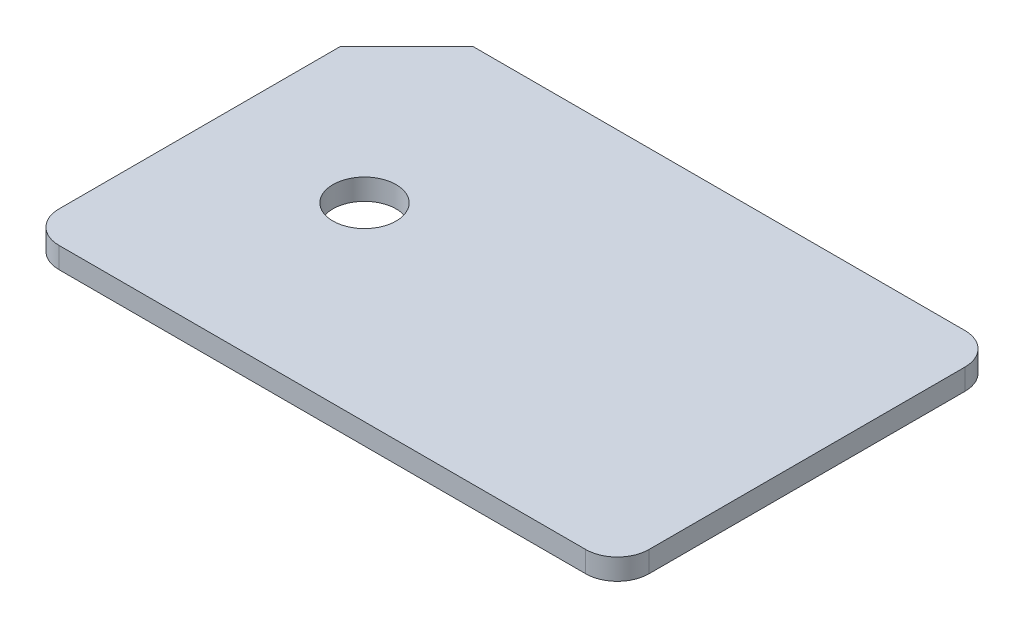
from build123d import *

# Parameters (mm, degrees)
BOSS_EXTRUDE1_DEPTH = 2
SKETCH3_R           = 2.999590147
CUT_EXTRUDE1_DEPTH  = 2


with BuildPart() as part:
    # Sketch1 → Boss-Extrude1 (new body)
    with BuildSketch(Plane(origin=(0, 0, 0), x_dir=(1, 0, 0), z_dir=(0, 1, 0))):
        with BuildLine():
            Line((-56.662746608, 29.55617923), (-50.334319483, 35.884606354))
            Line((-50.334319483, 35.884606354), (-3.662746608, 35.884606354))
            ThreePointArc((-3.662746608, 35.884606354), (-1.541426264, 35.005926698), (-0.662746608, 32.884606354))
            Line((-0.662746608, 32.884606354), (-0.662746608, 2.884606354))
            ThreePointArc((-0.662746608, 2.884606354), (-1.541426264, 0.763286011), (-3.662746608, -0.115393646))
            Line((-3.662746608, -0.115393646), (-53.662746608, -0.115393646))
            ThreePointArc((-53.662746608, -0.115393646), (-55.784066951, 0.763286011), (-56.662746608, 2.884606354))
            Line((-56.662746608, 2.884606354), (-56.662746608, 29.55617923))
        make_face()
    extrude(amount=BOSS_EXTRUDE1_DEPTH)

    # Sketch3 → Cut-Extrude1 (cut)
    with BuildSketch(Plane(origin=(0, 2, 0), x_dir=(1, 0, 0), z_dir=(0, 1, 0))):
        with Locations((-42.662746608, 17.884606354)):
            Circle(SKETCH3_R)
    extrude(amount=-CUT_EXTRUDE1_DEPTH, mode=Mode.SUBTRACT)


solid = part.part
